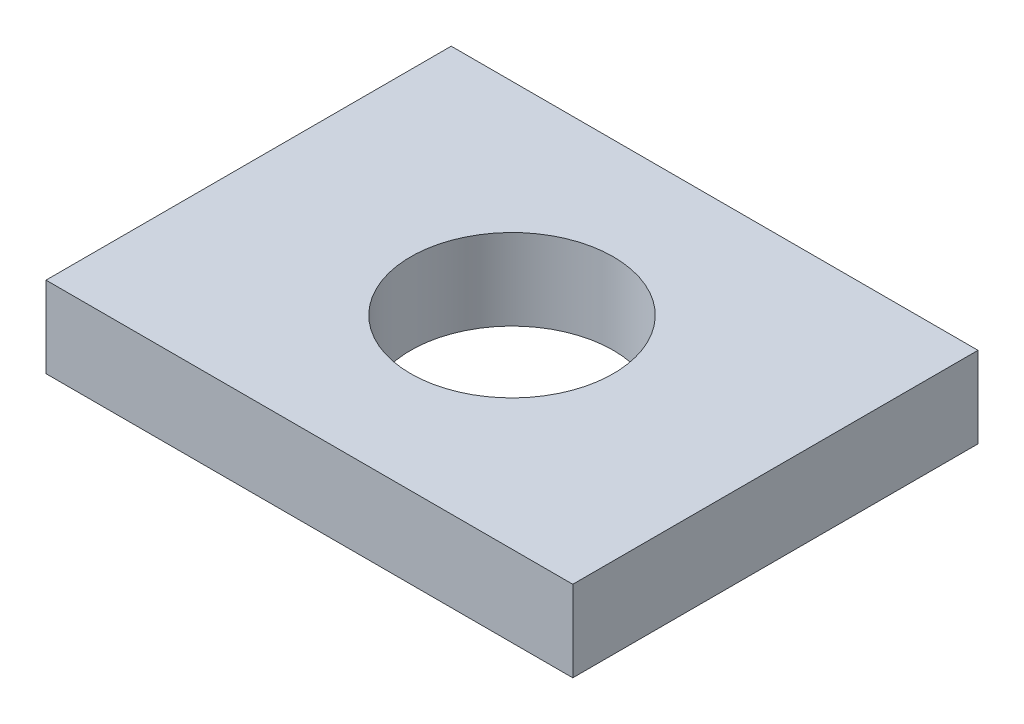
from build123d import *

# Parameters (mm, degrees)
CROQUIS1_W              = 13
CROQUIS1_H              = 10
CROQUIS1_R              = 2.5
SALIENTE_EXTRUIR1_DEPTH = 2


with BuildPart() as part:
    # Croquis1 → Saliente-Extruir1 (new body)
    with BuildSketch(Plane(origin=(0, 0, 0), x_dir=(1, 0, 0), z_dir=(0, 1, 0))):
        Rectangle(CROQUIS1_W, CROQUIS1_H)
        Circle(CROQUIS1_R, mode=Mode.SUBTRACT)
    extrude(amount=SALIENTE_EXTRUIR1_DEPTH)


solid = part.part
